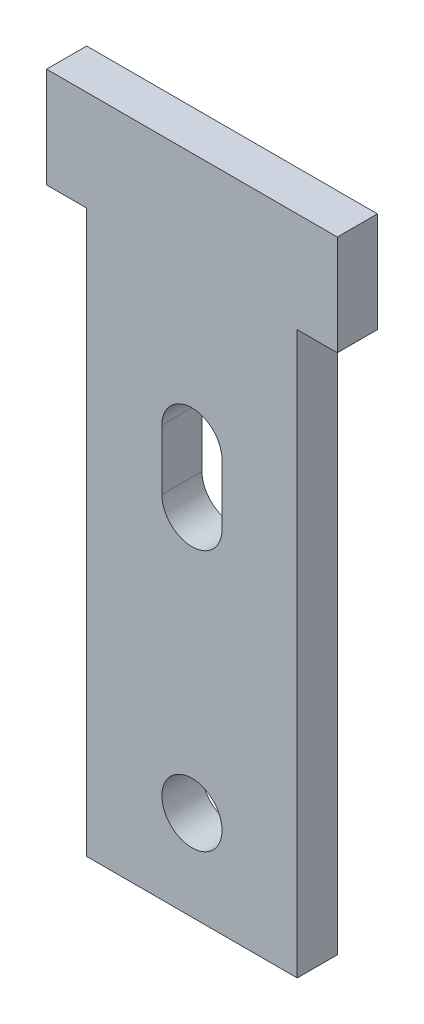
from build123d import *

# Parameters (mm, degrees)
SKETCH1_W           = 13.335
SKETCH1_H           = 2.54
BOSS_EXTRUDE1_DEPTH = 35.56
BOSS_EXTRUDE2_DEPTH = 2.54
CUT_EXTRUDE1_REACH  = 4.54
SKETCH3_R           = 1.905


with BuildPart() as part:
    # Sketch1 → Boss-Extrude1 (new body)
    with BuildSketch(Plane(origin=(0, 0, 0), x_dir=(1, 0, 0), z_dir=(0, 1, 0))):
        Rectangle(SKETCH1_W, SKETCH1_H)
    extrude(amount=BOSS_EXTRUDE1_DEPTH)

    # Sketch2 → Boss-Extrude2 (add)
    with BuildSketch(Plane.XY.offset(1.27)):
        Polygon((-9.2075, 35.56), (-6.6675, 35.56), (6.6675, 35.56), (9.2075, 35.56), (9.2075, 41.91), (-9.2075, 41.91), align=None)
    extrude(amount=-BOSS_EXTRUDE2_DEPTH)

    # Sketch3 → Cut-Extrude1 (cut, up to next)
    with BuildSketch(Plane.XY.offset(1.27), mode=Mode.PRIVATE) as cut_extrude1_sk1:
        with Locations((0, 5.715)):
            Circle(SKETCH3_R)
    cut_extrude1_tool1 = extrude(cut_extrude1_sk1.sketch, amount=-CUT_EXTRUDE1_REACH, mode=Mode.PRIVATE) & part.part
    add(cut_extrude1_tool1.solids().sort_by_distance((0, 5.715, 1.27))[0], mode=Mode.SUBTRACT)
    # Sketch3 → Cut-Extrude1 (cut, up to next)
    with BuildSketch(Plane.XY.offset(1.27), mode=Mode.PRIVATE) as cut_extrude1_sk2:
        with BuildLine():
            Line((1.905, 26.035), (1.905, 22.225))
            ThreePointArc((1.905, 22.225), (0, 20.32), (-1.905, 22.225))
            Line((-1.905, 22.225), (-1.905, 26.035))
            ThreePointArc((-1.905, 26.035), (0, 27.94), (1.905, 26.035))
        make_face()
    cut_extrude1_tool2 = extrude(cut_extrude1_sk2.sketch, amount=-CUT_EXTRUDE1_REACH, mode=Mode.PRIVATE) & part.part
    add(cut_extrude1_tool2.solids().sort_by_distance((0, 24.13, 1.27))[0], mode=Mode.SUBTRACT)


solid = part.part
